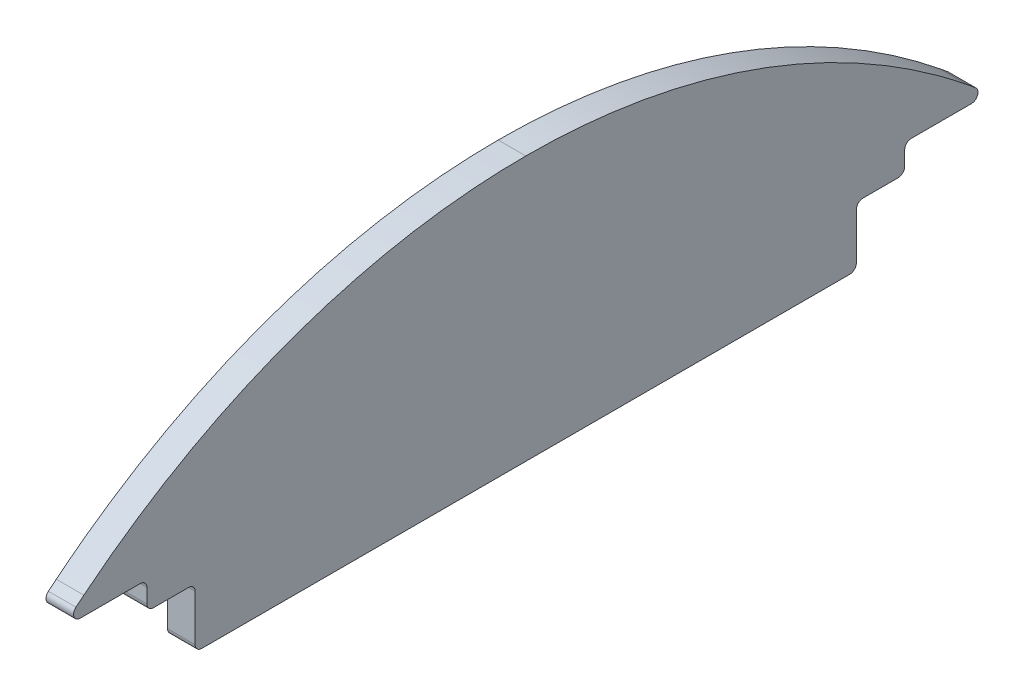
from build123d import *

# Parameters (mm, degrees)
BOSS_EXTRUDE1_DEPTH = 3.175
SKETCH1_3_W         = 76.2
SKETCH1_3_H         = 6.843416336
BOSS_EXTRUDE2_DEPTH = 3.175
FILLET1_R           = 0.762


with BuildPart() as part:
    # Sketch1 → Boss-Extrude1 (new body)
    with BuildSketch(Plane(origin=(0, 0, 0), x_dir=(0, 0, -1), z_dir=(1, 0, 0))):
        with BuildLine():
            Line((-43.663217685, -8.64329225), (-43.663217685, -11.81829225))
            Line((-43.663217685, -11.81829225), (-38.1, -11.81829225))
            Line((-38.1, -11.81829225), (38.1, -11.81829225))
            Line((38.1, -11.81829225), (43.663218279, -11.81829225))
            Line((43.663218279, -11.81829225), (43.663218279, -8.64329225))
            Line((43.663218279, -8.64329225), (53.425755965, -8.64329225))
            add(Edge.make_bspline(
                [(53.425755965, -8.64329225), (53.263215222, -8.501846261), (52.438865838, -7.790883032), (51.598732776, -7.098646879), (50.924889325, -6.543426735)],
                knots=[0.589295503, 0.589295503, 0.589295503, 0.589295503, 0.670587257, 1, 1, 1, 1], degree=3))
            add(Edge.make_bspline(
                [(50.924889325, -6.543426735), (50.124144808, -5.909206331), (48.528125823, -4.645098009), (46.059087128, -2.864191401), (43.549887667, -1.177645044), (40.997889023, 0.406107926), (38.408155063, 1.888342774), (35.783665586, 3.267940071), (33.127912186, 4.544590036), (30.444209343, 5.717936201), (27.735877167, 6.787796608), (25.006192871, 7.754099696), (22.258403703, 8.616894329), (19.495723603, 9.376346971), (16.721334228, 10.032717883), (13.938384845, 10.586434135), (11.149992554, 11.03779968), (8.359242424, 11.388052771), (5.569187679, 11.635427625), (2.782849792, 11.78974762), (0.926482231, 11.808788455), (1.344e-06, 11.818291406)],
                knots=[0, 0, 0, 0, 0.055514859, 0.110650485, 0.165414313, 0.219814889, 0.273861748, 0.327565289, 0.380936647, 0.43398757, 0.486730286, 0.53917738, 0.59134167, 0.643236089, 0.694873565, 0.746266915, 0.797428738, 0.848371322, 0.899106551, 0.949645827, 1, 1, 1, 1], degree=3))
            add(Edge.make_bspline(
                [(1.344e-06, 11.818291406), (-0.978048688, 11.807700808), (-2.937955589, 11.78647839), (-5.879617768, 11.614460814), (-8.825050086, 11.338662737), (-11.770693383, 10.948099308), (-14.712949005, 10.444720364), (-17.648178684, 9.827137854), (-20.57270433, 9.095020044), (-23.482807764, 8.247912067), (-26.374730804, 7.285560858), (-29.244674098, 6.207832855), (-32.088800801, 5.014747428), (-34.903222204, 3.706458544), (-37.684051606, 2.283328938), (-40.427201271, 0.74568464), (-43.129148213, -0.90523213), (-45.784047279, -2.670825623), (-48.3946206, -4.541678592), (-50.079432356, -5.874568434), (-50.924883817, -6.543422779)],
                knots=[0, 0, 0, 0, 0.053156962, 0.106520825, 0.160104405, 0.213921194, 0.267985268, 0.32231118, 0.376913837, 0.431808373, 0.48701001, 0.542533909, 0.598395017, 0.654607907, 0.711186615, 0.76814447, 0.825493932, 0.883246422, 0.941412159, 1, 1, 1, 1], degree=3))
            add(Edge.make_bspline(
                [(-50.924883817, -6.543422779), (-51.598727834, -7.098643313), (-52.438862565, -7.790880746), (-53.263213559, -8.501845329), (-53.425755371, -8.64329225)],
                knots=[0, 0, 0, 0, 0.32941274, 0.410704965, 0.410704965, 0.410704965, 0.410704965], degree=3))
            Line((-53.425755371, -8.64329225), (-43.663217685, -8.64329225))
        make_face()
    extrude(amount=-BOSS_EXTRUDE1_DEPTH)

    # Sketch1_3 → Boss-Extrude2 (add)
    with BuildSketch(Plane(origin=(0, 0, 0), x_dir=(0, 0, -1), z_dir=(1, 0, 0))):
        with Locations((0, -15.240000418)):
            Rectangle(SKETCH1_3_W, SKETCH1_3_H)
    extrude(amount=-BOSS_EXTRUDE2_DEPTH)

    # Fillet1
    fillet1_edges = [part.edges().sort_by_distance(p)[0] for p in [
        (-1.5875, -8.64329225, -53.425755965),
        (-1.5875, -8.64329225, -43.663218279),
        (-1.5875, -11.81829225, -43.663218279),
        (-1.5875, -11.81829225, 43.663217685),
        (-1.5875, -8.64329225, 43.663217685),
        (-1.5875, -8.64329225, 53.425755371),
        (-1.5875, -18.661708586, -38.1),
        (-1.5875, -11.81829225, -38.1),
        (-1.5875, -18.661708586, 38.1),
        (-1.5875, -11.81829225, 38.1),
    ]]
    fillet(fillet1_edges, radius=FILLET1_R)


solid = part.part
